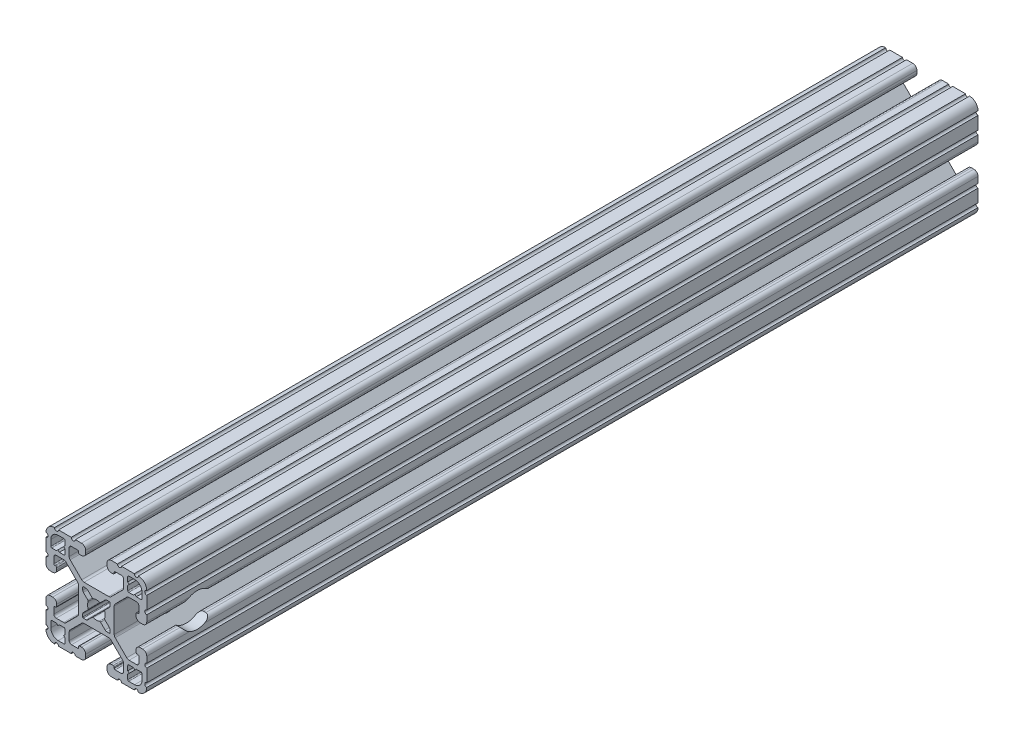
from build123d import *

# Parameters (mm, degrees)
BOSS_EXTRUDE1_DEPTH = 314.325
SKETCH2_R           = 6.35
CUT_EXTRUDE1_DEPTH  = 39.100000018


with BuildPart() as part:
    # Sketch1 → Boss-Extrude1 (new body)
    with BuildSketch(Plane(origin=(0, 0, -2322.576), x_dir=(-1, 0, 0), z_dir=(0, 0, -1))):
        with BuildLine():
            Line((19.05, -14.325600033), (19.05, -9.4996))
            ThreePointArc((19.05, -9.4996), (18.288, -8.7376), (19.05, -7.9756))
            Line((19.05, -7.9756), (19.05, -5.6388))
            ThreePointArc((19.05, -5.6388), (18.588751759, -4.525248241), (17.4752, -4.064))
            Line((17.4752, -4.064), (16.5608, -4.064))
            ThreePointArc((16.5608, -4.064), (15.447248241, -4.525248241), (14.986, -5.6388))
            Line((14.986, -5.6388), (14.986, -6.350014224))
            ThreePointArc((14.986, -6.350014224), (15.097592316, -6.619421908), (15.367, -6.731014224))
            Line((15.367, -6.731014224), (15.6972, -6.731014224))
            ThreePointArc((15.6972, -6.731014224), (15.966607684, -6.84260654), (16.0782, -7.112014224))
            Line((16.0782, -7.112014224), (16.0782, -9.398014224))
            ThreePointArc((16.0782, -9.398014224), (15.817817928, -10.026632152), (15.1892, -10.287014224))
            Line((15.1892, -10.287014224), (12.375630013, -10.287014224))
            ThreePointArc((12.375630013, -10.287014224), (11.889622054, -10.19034123), (11.477604401, -9.915039836))
            Line((11.477604401, -9.915039836), (7.115699788, -5.553135223))
            ThreePointArc((7.115699788, -5.553135223), (6.840398394, -5.14111757), (6.7437254, -4.655109611))
            Line((6.7437254, -4.655109611), (6.7437254, 4.655109611))
            ThreePointArc((6.7437254, 4.655109611), (6.840398394, 5.14111757), (7.115699788, 5.553135223))
            Line((7.115699788, 5.553135223), (11.477604401, 9.915039836))
            ThreePointArc((11.477604401, 9.915039836), (11.889622054, 10.19034123), (12.375630013, 10.287014224))
            Line((12.375630013, 10.287014224), (15.1892, 10.287014224))
            ThreePointArc((15.1892, 10.287014224), (15.817817928, 10.026632152), (16.0782, 9.398014224))
            Line((16.0782, 9.398014224), (16.0782, 7.112014224))
            ThreePointArc((16.0782, 7.112014224), (15.966607684, 6.84260654), (15.6972, 6.731014224))
            Line((15.6972, 6.731014224), (15.367, 6.731014224))
            ThreePointArc((15.367, 6.731014224), (15.097592316, 6.619421908), (14.986, 6.350014224))
            Line((14.986, 6.350014224), (14.986, 5.6388))
            ThreePointArc((14.986, 5.6388), (15.447248241, 4.525248241), (16.5608, 4.064))
            Line((16.5608, 4.064), (17.4752, 4.064))
            ThreePointArc((17.4752, 4.064), (18.588751759, 4.525248241), (19.05, 5.6388))
            Line((19.05, 5.6388), (19.05, 7.9756))
            ThreePointArc((19.05, 7.9756), (18.288, 8.7376), (19.05, 9.4996))
            Line((19.05, 9.4996), (19.05, 14.325599984))
            ThreePointArc((19.05, 14.325599984), (18.287999986, 15.087549208), (19.049898416, 15.849600009))
            ThreePointArc((19.049898416, 15.849600009), (18.120064036, 18.120064058), (15.849599977, 19.049898414))
            ThreePointArc((15.849599977, 19.049898414), (15.0875492, 18.288000035), (14.325600017, 19.050000016))
            Line((14.325600017, 19.050000016), (9.499600001, 19.050000016))
            ThreePointArc((9.499600001, 19.050000016), (8.737600001, 18.288000016), (7.975600001, 19.050000016))
            Line((7.975600001, 19.050000016), (5.638800016, 19.050000016))
            ThreePointArc((5.638800016, 19.050000016), (4.525248257, 18.588751775), (4.064000016, 17.475200016))
            Line((4.064000016, 17.475200016), (4.064000016, 16.5608))
            ThreePointArc((4.064000016, 16.5608), (4.525248257, 15.447248241), (5.638800016, 14.986))
            Line((5.638800016, 14.986), (6.350014224, 14.986))
            ThreePointArc((6.350014224, 14.986), (6.619421908, 15.097592316), (6.731014224, 15.367))
            Line((6.731014224, 15.367), (6.731014224, 15.6972))
            ThreePointArc((6.731014224, 15.6972), (6.84260654, 15.966607684), (7.112014224, 16.0782))
            Line((7.112014224, 16.0782), (9.398014224, 16.0782))
            ThreePointArc((9.398014224, 16.0782), (10.026632152, 15.817817928), (10.287014224, 15.1892))
            Line((10.287014224, 15.1892), (10.287014224, 12.375630013))
            ThreePointArc((10.287014224, 12.375630013), (10.19034123, 11.889622054), (9.915039836, 11.477604401))
            Line((9.915039836, 11.477604401), (5.553135223, 7.115699788))
            ThreePointArc((5.553135223, 7.115699788), (5.14111757, 6.840398394), (4.655109611, 6.7437254))
            Line((4.655109611, 6.7437254), (-4.655109611, 6.7437254))
            ThreePointArc((-4.655109611, 6.7437254), (-5.14111757, 6.840398394), (-5.553135223, 7.115699788))
            Line((-5.553135223, 7.115699788), (-9.915039836, 11.477604401))
            ThreePointArc((-9.915039836, 11.477604401), (-10.19034123, 11.889622054), (-10.287014224, 12.375630013))
            Line((-10.287014224, 12.375630013), (-10.287014224, 15.1892))
            ThreePointArc((-10.287014224, 15.1892), (-10.026632152, 15.817817928), (-9.398014224, 16.0782))
            Line((-9.398014224, 16.0782), (-7.112014224, 16.0782))
            ThreePointArc((-7.112014224, 16.0782), (-6.84260654, 15.966607684), (-6.731014224, 15.6972))
            Line((-6.731014224, 15.6972), (-6.731014224, 15.367))
            ThreePointArc((-6.731014224, 15.367), (-6.619421908, 15.097592316), (-6.350014224, 14.986))
            Line((-6.350014224, 14.986), (-5.638799984, 14.986))
            ThreePointArc((-5.638799984, 14.986), (-4.525248225, 15.447248241), (-4.063999984, 16.5608))
            Line((-4.063999984, 16.5608), (-4.063999984, 17.475200016))
            ThreePointArc((-4.063999984, 17.475200016), (-4.525248225, 18.588751775), (-5.638799984, 19.050000016))
            Line((-5.638799984, 19.050000016), (-7.975599999, 19.050000016))
            ThreePointArc((-7.975599999, 19.050000016), (-8.737599999, 18.288000016), (-9.499599999, 19.050000016))
            Line((-9.499599999, 19.050000016), (-14.325599999, 19.050000016))
            ThreePointArc((-14.325599999, 19.050000016), (-15.087549199, 18.288000018), (-15.849599993, 19.049898416))
            ThreePointArc((-15.849599993, 19.049898416), (-18.120064042, 18.120064036), (-19.049898398, 15.849599976))
            ThreePointArc((-19.049898398, 15.849599976), (-18.288000019, 15.087549199), (-19.05, 14.325600017))
            Line((-19.05, 14.325600017), (-19.05, 9.4996))
            ThreePointArc((-19.05, 9.4996), (-18.288, 8.7376), (-19.05, 7.9756))
            Line((-19.05, 7.9756), (-19.05, 5.6388))
            ThreePointArc((-19.05, 5.6388), (-18.588751759, 4.525248241), (-17.4752, 4.064))
            Line((-17.4752, 4.064), (-16.5608, 4.064))
            ThreePointArc((-16.5608, 4.064), (-15.447248241, 4.525248241), (-14.986, 5.6388))
            Line((-14.986, 5.6388), (-14.986, 6.350014224))
            ThreePointArc((-14.986, 6.350014224), (-15.097592316, 6.619421908), (-15.367, 6.731014224))
            Line((-15.367, 6.731014224), (-15.6972, 6.731014224))
            ThreePointArc((-15.6972, 6.731014224), (-15.966607684, 6.84260654), (-16.0782, 7.112014224))
            Line((-16.0782, 7.112014224), (-16.0782, 9.398014224))
            ThreePointArc((-16.0782, 9.398014224), (-15.817817928, 10.026632152), (-15.1892, 10.287014224))
            Line((-15.1892, 10.287014224), (-12.375630013, 10.287014224))
            ThreePointArc((-12.375630013, 10.287014224), (-11.889622054, 10.19034123), (-11.477604401, 9.915039836))
            Line((-11.477604401, 9.915039836), (-7.115699788, 5.553135223))
            ThreePointArc((-7.115699788, 5.553135223), (-6.840398394, 5.14111757), (-6.7437254, 4.655109611))
            Line((-6.7437254, 4.655109611), (-6.7437254, -4.655109611))
            ThreePointArc((-6.7437254, -4.655109611), (-6.840398394, -5.14111757), (-7.115699788, -5.553135223))
            Line((-7.115699788, -5.553135223), (-11.477604401, -9.915039836))
            ThreePointArc((-11.477604401, -9.915039836), (-11.889622054, -10.19034123), (-12.375630013, -10.287014224))
            Line((-12.375630013, -10.287014224), (-15.1892, -10.287014224))
            ThreePointArc((-15.1892, -10.287014224), (-15.817817928, -10.026632152), (-16.0782, -9.398014224))
            Line((-16.0782, -9.398014224), (-16.0782, -7.112014224))
            ThreePointArc((-16.0782, -7.112014224), (-15.966607684, -6.84260654), (-15.6972, -6.731014224))
            Line((-15.6972, -6.731014224), (-15.367, -6.731014224))
            ThreePointArc((-15.367, -6.731014224), (-15.097592316, -6.619421908), (-14.986, -6.350014224))
            Line((-14.986, -6.350014224), (-14.986, -5.6388))
            ThreePointArc((-14.986, -5.6388), (-15.447248241, -4.525248241), (-16.5608, -4.064))
            Line((-16.5608, -4.064), (-17.4752, -4.064))
            ThreePointArc((-17.4752, -4.064), (-18.588751759, -4.525248241), (-19.05, -5.6388))
            Line((-19.05, -5.6388), (-19.05, -7.9756))
            ThreePointArc((-19.05, -7.9756), (-18.288, -8.7376), (-19.05, -9.4996))
            Line((-19.05, -9.4996), (-19.05, -14.3256))
            ThreePointArc((-19.05, -14.3256), (-18.288000002, -15.0875492), (-19.0498984, -15.849599993))
            ThreePointArc((-19.0498984, -15.849599993), (-18.120064019, -18.120064043), (-15.84959996, -19.049898399))
            ThreePointArc((-15.84959996, -19.049898399), (-15.087549183, -18.288000019), (-14.325600001, -19.050000001))
            Line((-14.325600001, -19.050000001), (-9.499599984, -19.050000001))
            ThreePointArc((-9.499599984, -19.050000001), (-8.737599984, -18.288000001), (-7.975599984, -19.050000001))
            Line((-7.975599984, -19.050000001), (-5.638799984, -19.050000001))
            ThreePointArc((-5.638799984, -19.050000001), (-4.525248225, -18.58875176), (-4.063999984, -17.475200001))
            Line((-4.063999984, -17.475200001), (-4.063999984, -16.5608))
            ThreePointArc((-4.063999984, -16.5608), (-4.525248225, -15.447248241), (-5.638799984, -14.986))
            Line((-5.638799984, -14.986), (-6.350014224, -14.986))
            ThreePointArc((-6.350014224, -14.986), (-6.619421908, -15.097592316), (-6.731014224, -15.367))
            Line((-6.731014224, -15.367), (-6.731014224, -15.6972))
            ThreePointArc((-6.731014224, -15.6972), (-6.84260654, -15.966607684), (-7.112014224, -16.0782))
            Line((-7.112014224, -16.0782), (-9.398014224, -16.0782))
            ThreePointArc((-9.398014224, -16.0782), (-10.026632152, -15.817817928), (-10.287014224, -15.1892))
            Line((-10.287014224, -15.1892), (-10.287014224, -12.375630013))
            ThreePointArc((-10.287014224, -12.375630013), (-10.19034123, -11.889622054), (-9.915039836, -11.477604401))
            Line((-9.915039836, -11.477604401), (-5.553135223, -7.115699788))
            ThreePointArc((-5.553135223, -7.115699788), (-5.14111757, -6.840398394), (-4.655109611, -6.7437254))
            Line((-4.655109611, -6.7437254), (4.655109611, -6.7437254))
            ThreePointArc((4.655109611, -6.7437254), (5.14111757, -6.840398394), (5.553135223, -7.115699788))
            Line((5.553135223, -7.115699788), (9.915039836, -11.477604401))
            ThreePointArc((9.915039836, -11.477604401), (10.19034123, -11.889622054), (10.287014224, -12.375630013))
            Line((10.287014224, -12.375630013), (10.287014224, -15.1892))
            ThreePointArc((10.287014224, -15.1892), (10.026632152, -15.817817928), (9.398014224, -16.0782))
            Line((9.398014224, -16.0782), (7.112014224, -16.0782))
            ThreePointArc((7.112014224, -16.0782), (6.84260654, -15.966607684), (6.731014224, -15.6972))
            Line((6.731014224, -15.6972), (6.731014224, -15.367))
            ThreePointArc((6.731014224, -15.367), (6.619421908, -15.097592316), (6.350014224, -14.986))
            Line((6.350014224, -14.986), (5.638800016, -14.986))
            ThreePointArc((5.638800016, -14.986), (4.525248257, -15.447248241), (4.064000016, -16.5608))
            Line((4.064000016, -16.5608), (4.064000016, -17.475200001))
            ThreePointArc((4.064000016, -17.475200001), (4.525248257, -18.58875176), (5.638800016, -19.050000001))
            Line((5.638800016, -19.050000001), (7.975600016, -19.050000001))
            ThreePointArc((7.975600016, -19.050000001), (8.737600016, -18.288000001), (9.499600016, -19.050000001))
            Line((9.499600016, -19.050000001), (14.325600016, -19.050000001))
            ThreePointArc((14.325600016, -19.050000001), (15.087549216, -18.288000002), (15.849600009, -19.0498984))
            ThreePointArc((15.849600009, -19.0498984), (18.120064059, -18.12006402), (19.049898415, -15.849599961))
            ThreePointArc((19.049898415, -15.849599961), (18.288000034, -15.087549207), (19.05, -14.325600033))
        make_face()
        with BuildLine():
            Line((17.246614224, 14.452614224), (17.246614224, 12.242814224))
            ThreePointArc((17.246614224, 12.242814224), (17.135021908, 11.97340654), (16.865614224, 11.861814224))
            Line((16.865614224, 11.861814224), (15.092694224, 11.861814224))
            Line((15.092694224, 11.861814224), (14.554214224, 12.400294224))
            Line((14.554214224, 12.400294224), (14.015734224, 11.861814224))
            Line((14.015734224, 11.861814224), (12.242814224, 11.861814224))
            ThreePointArc((12.242814224, 11.861814224), (11.97340654, 11.97340654), (11.861814224, 12.242814224))
            Line((11.861814224, 12.242814224), (11.861814224, 14.015734224))
            Line((11.861814224, 14.015734224), (12.400294224, 14.554214224))
            Line((12.400294224, 14.554214224), (11.861814224, 15.092694224))
            Line((11.861814224, 15.092694224), (11.861814224, 16.865614224))
            ThreePointArc((11.861814224, 16.865614224), (11.97340654, 17.135021908), (12.242814224, 17.246614224))
            Line((12.242814224, 17.246614224), (14.452614224, 17.246614224))
            ThreePointArc((14.452614224, 17.246614224), (16.428270571, 16.428270571), (17.246614224, 14.452614224))
        make_face(mode=Mode.SUBTRACT)
        with BuildLine():
            Line((17.246614224, -12.242814224), (17.246614224, -14.452614224))
            ThreePointArc((17.246614224, -14.452614224), (16.428270571, -16.428270571), (14.452614224, -17.246614224))
            Line((14.452614224, -17.246614224), (12.242814224, -17.246614224))
            ThreePointArc((12.242814224, -17.246614224), (11.97340654, -17.135021908), (11.861814224, -16.865614224))
            Line((11.861814224, -16.865614224), (11.861814224, -15.092694224))
            Line((11.861814224, -15.092694224), (12.400294224, -14.554214224))
            Line((12.400294224, -14.554214224), (11.861814224, -14.015734224))
            Line((11.861814224, -14.015734224), (11.861814224, -12.242814224))
            ThreePointArc((11.861814224, -12.242814224), (11.97340654, -11.97340654), (12.242814224, -11.861814224))
            Line((12.242814224, -11.861814224), (14.015734224, -11.861814224))
            Line((14.015734224, -11.861814224), (14.554214224, -12.400294224))
            Line((14.554214224, -12.400294224), (15.092694224, -11.861814224))
            Line((15.092694224, -11.861814224), (16.865614224, -11.861814224))
            ThreePointArc((16.865614224, -11.861814224), (17.135021908, -11.97340654), (17.246614224, -12.242814224))
        make_face(mode=Mode.SUBTRACT)
        with BuildLine():
            Line((5.1689, -3.920689755), (5.1689, -4.9149))
            ThreePointArc((5.1689, -4.9149), (5.094505122, -5.094505122), (4.9149, -5.1689))
            Line((4.9149, -5.1689), (3.920689755, -5.1689))
            ThreePointArc((3.920689755, -5.1689), (3.580484184, -5.101228904), (3.292071827, -4.908517928))
            Line((3.292071827, -4.908517928), (1.582347442, -3.198793543))
            ThreePointArc((1.582347442, -3.198793543), (1.393016011, -3.095711236), (1.178048687, -3.111879183))
            ThreePointArc((1.178048687, -3.111879183), (0, -3.3274), (-1.178048687, -3.111879183))
            ThreePointArc((-1.178048687, -3.111879183), (-1.393016011, -3.095711236), (-1.582347442, -3.198793543))
            Line((-1.582347442, -3.198793543), (-3.292071827, -4.908517928))
            ThreePointArc((-3.292071827, -4.908517928), (-3.580484184, -5.101228904), (-3.920689755, -5.1689))
            Line((-3.920689755, -5.1689), (-4.9149, -5.1689))
            ThreePointArc((-4.9149, -5.1689), (-5.094505122, -5.094505122), (-5.1689, -4.9149))
            Line((-5.1689, -4.9149), (-5.1689, -3.920689755))
            ThreePointArc((-5.1689, -3.920689755), (-5.101228904, -3.580484184), (-4.908517928, -3.292071827))
            Line((-4.908517928, -3.292071827), (-3.198793543, -1.582347442))
            ThreePointArc((-3.198793543, -1.582347442), (-3.095711236, -1.393016011), (-3.111879183, -1.178048687))
            ThreePointArc((-3.111879183, -1.178048687), (-3.3274, 0), (-3.111879183, 1.178048687))
            ThreePointArc((-3.111879183, 1.178048687), (-3.095711236, 1.393016011), (-3.198793543, 1.582347442))
            Line((-3.198793543, 1.582347442), (-4.908517928, 3.292071827))
            ThreePointArc((-4.908517928, 3.292071827), (-5.101228904, 3.580484184), (-5.1689, 3.920689755))
            Line((-5.1689, 3.920689755), (-5.1689, 4.9149))
            ThreePointArc((-5.1689, 4.9149), (-5.094505122, 5.094505122), (-4.9149, 5.1689))
            Line((-4.9149, 5.1689), (-3.920689755, 5.1689))
            ThreePointArc((-3.920689755, 5.1689), (-3.580484184, 5.101228904), (-3.292071827, 4.908517928))
            Line((-3.292071827, 4.908517928), (-1.582347442, 3.198793543))
            ThreePointArc((-1.582347442, 3.198793543), (-1.393016011, 3.095711236), (-1.178048687, 3.111879183))
            ThreePointArc((-1.178048687, 3.111879183), (0, 3.3274), (1.178048687, 3.111879183))
            ThreePointArc((1.178048687, 3.111879183), (1.393016011, 3.095711236), (1.582347442, 3.198793543))
            Line((1.582347442, 3.198793543), (3.292071827, 4.908517928))
            ThreePointArc((3.292071827, 4.908517928), (3.580484184, 5.101228904), (3.920689755, 5.1689))
            Line((3.920689755, 5.1689), (4.9149, 5.1689))
            ThreePointArc((4.9149, 5.1689), (5.094505122, 5.094505122), (5.1689, 4.9149))
            Line((5.1689, 4.9149), (5.1689, 3.920689755))
            ThreePointArc((5.1689, 3.920689755), (5.101228904, 3.580484184), (4.908517928, 3.292071827))
            Line((4.908517928, 3.292071827), (3.198793543, 1.582347442))
            ThreePointArc((3.198793543, 1.582347442), (3.095711236, 1.393016011), (3.111879183, 1.178048687))
            ThreePointArc((3.111879183, 1.178048687), (3.3274, 0), (3.111879183, -1.178048687))
            ThreePointArc((3.111879183, -1.178048687), (3.095711236, -1.393016011), (3.198793543, -1.582347442))
            Line((3.198793543, -1.582347442), (4.908517928, -3.292071827))
            ThreePointArc((4.908517928, -3.292071827), (5.101228904, -3.580484184), (5.1689, -3.920689755))
        make_face(mode=Mode.SUBTRACT)
        with BuildLine():
            Line((-11.861814224, -12.242814224), (-11.861814224, -14.015734224))
            Line((-11.861814224, -14.015734224), (-12.400294224, -14.554214224))
            Line((-12.400294224, -14.554214224), (-11.861814224, -15.092694224))
            Line((-11.861814224, -15.092694224), (-11.861814224, -16.865614224))
            ThreePointArc((-11.861814224, -16.865614224), (-11.97340654, -17.135021908), (-12.242814224, -17.246614224))
            Line((-12.242814224, -17.246614224), (-14.452614224, -17.246614224))
            ThreePointArc((-14.452614224, -17.246614224), (-16.428270571, -16.428270571), (-17.246614224, -14.452614224))
            Line((-17.246614224, -14.452614224), (-17.246614224, -12.242814224))
            ThreePointArc((-17.246614224, -12.242814224), (-17.135021908, -11.97340654), (-16.865614224, -11.861814224))
            Line((-16.865614224, -11.861814224), (-15.092694224, -11.861814224))
            Line((-15.092694224, -11.861814224), (-14.554214224, -12.400294224))
            Line((-14.554214224, -12.400294224), (-14.015734224, -11.861814224))
            Line((-14.015734224, -11.861814224), (-12.242814224, -11.861814224))
            ThreePointArc((-12.242814224, -11.861814224), (-11.97340654, -11.97340654), (-11.861814224, -12.242814224))
        make_face(mode=Mode.SUBTRACT)
        with BuildLine():
            Line((-11.861814224, 16.865614224), (-11.861814224, 15.092694224))
            Line((-11.861814224, 15.092694224), (-12.400294224, 14.554214224))
            Line((-12.400294224, 14.554214224), (-11.861814224, 14.015734224))
            Line((-11.861814224, 14.015734224), (-11.861814224, 12.242814224))
            ThreePointArc((-11.861814224, 12.242814224), (-11.97340654, 11.97340654), (-12.242814224, 11.861814224))
            Line((-12.242814224, 11.861814224), (-14.015734224, 11.861814224))
            Line((-14.015734224, 11.861814224), (-14.554214224, 12.400294224))
            Line((-14.554214224, 12.400294224), (-15.092694224, 11.861814224))
            Line((-15.092694224, 11.861814224), (-16.865614224, 11.861814224))
            ThreePointArc((-16.865614224, 11.861814224), (-17.135021908, 11.97340654), (-17.246614224, 12.242814224))
            Line((-17.246614224, 12.242814224), (-17.246614224, 14.452614224))
            ThreePointArc((-17.246614224, 14.452614224), (-16.428270571, 16.428270571), (-14.452614224, 17.246614224))
            Line((-14.452614224, 17.246614224), (-12.242814224, 17.246614224))
            ThreePointArc((-12.242814224, 17.246614224), (-11.97340654, 17.135021908), (-11.861814224, 16.865614224))
        make_face(mode=Mode.SUBTRACT)
    extrude(amount=-BOSS_EXTRUDE1_DEPTH)

    # Sketch2 → Cut-Extrude1 (cut, through all)
    with BuildSketch(Plane(origin=(19.05, 0, 0), x_dir=(0, 0, -1), z_dir=(1, 0, 0))):
        with Locations((2027.301, 0)):
            Circle(SKETCH2_R)
    extrude(amount=-CUT_EXTRUDE1_DEPTH, mode=Mode.SUBTRACT)


solid = part.part
